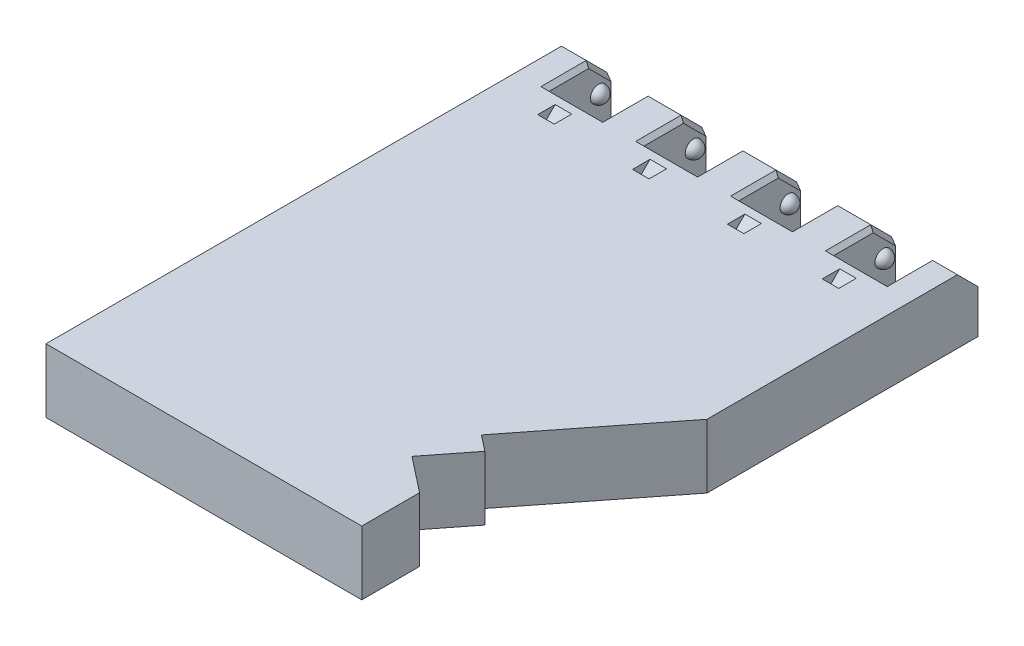
from build123d import *

# Parameters (mm, degrees)
BOSS_EXTRUDE1_DEPTH     = 15.5
SKETCH10_W              = 4
SKETCH10_H              = 30
CUT_EXTRUDE1_DEPTH      = 3
MIRROR5_COPY_1_SKETCH_W = 4
MIRROR5_COPY_1_SKETCH_H = 30
MIRROR5_COPY_1_DEPTH    = 3
SKETCH14_W              = 2.751713212
SKETCH14_H              = 4
BOSS_EXTRUDE2_DEPTH     = 4
SKETCH15_W              = 4.497862048
SKETCH15_H              = 7
BOSS_EXTRUDE3_DEPTH     = 1
MIRROR7_COPY_1_SKETCH_W = 2.751713212
MIRROR7_COPY_1_SKETCH_H = 4
MIRROR7_COPY_1_DEPTH    = 4
MIRROR7_COPY_2_SKETCH_W = 4.497862048
MIRROR7_COPY_2_SKETCH_H = 7
MIRROR7_COPY_2_DEPTH    = 1
CHAMFER9_SIZE           = 5
CHAMFER10_SIZE          = 1
CHAMFER15_SIZE          = 5
CHAMFER16_SIZE          = 1
CHAMFER17_SIZE          = 1
CHAMFER18_SIZE          = 5
CHAMFER19_SIZE          = 1


with BuildPart() as part:
    # Sketch1 → Boss-Extrude1 (new body)
    with BuildSketch(Plane(origin=(0, 0, 0), x_dir=(1, 0, 0), z_dir=(0, 1, 0))):
        Polygon((-106.77339112, 72.768445428), (-99.77339112, 72.768445428), (-99.77339112, 56.768445428), (-86.77339112, 56.768445428), (-86.77339112, 72.768445428), (-76.77339112, 72.768445428), (-76.77339112, 56.768445428), (-63.77339112, 56.768445428), (-63.77339112, 72.768445428), (-53.77339112, 72.768445428), (-53.77339112, 56.768445428), (-40.77339112, 56.768445428), (-40.77339112, 72.768445428), (-30.77339112, 72.768445428), (-30.77339112, 56.768445428), (-17.77339112, 56.768445428), (-17.77339112, 72.768445428), (-10.77339112, 72.768445428), (-10.77339112, 7.054306764), (-34.835725148, -23.581828326), (-30.98324076, -26.60765929), (-38.753655744, -36.500942414), (-30.205167067, -43.215124519), (-30.205167067, -57.231554572), (-106.77339112, -57.231554572), align=None)
    extrude(amount=BOSS_EXTRUDE1_DEPTH)

    # Sketch4 → Revolve1 (revolve)
    with BuildSketch(Plane(origin=(-99.77339112, 0, 0), x_dir=(0, 0, -1), z_dir=(1, 0, 0))):
        with BuildLine():
            Line((67.768445428, 8), (71.768445428, 8))
            ThreePointArc((71.768445428, 8), (69.768445428, 10), (67.768445428, 8))
        make_face()
    revolve1 = revolve(axis=Axis((-99.77339112, 8, -67.768445428), (0, 0, -1)))

    # Mirror1: Revolve1 across plane
    add(revolve1.mirror(Plane(origin=(-93.27339112, 0, 0), x_dir=(0, 0, 1), z_dir=(1, 0, 0))))

    # Mirror2: Revolve1 across plane
    add(revolve1.mirror(Plane(origin=(-81.77339112, 0, 0), x_dir=(0, 0, 1), z_dir=(1, 0, 0))))

    # Mirror2 copy 1 sketch → Mirror2 copy 1 (revolve)
    with BuildSketch(Plane(origin=(-76.77339112, 0, 0), x_dir=(0, 0, -1), z_dir=(1, 0, 0))):
        with BuildLine():
            Line((67.768445428, 8), (71.768445428, 8))
            ThreePointArc((71.768445428, 8), (69.768445428, 10), (67.768445428, 8))
        make_face()
    revolve(axis=Axis((-76.77339112, 8, -67.768445428), (0, 0, -1)))

    # Mirror3: Revolve1 across plane
    add(revolve1.mirror(Plane(origin=(-58.77339112, 0, 0), x_dir=(0, 0, 1), z_dir=(1, 0, 0))))

    # Mirror3 copy 1 sketch → Mirror3 copy 1 (revolve)
    with BuildSketch(Plane(origin=(-53.77339112, 0, 0), x_dir=(0, 0, -1), z_dir=(1, 0, 0))):
        with BuildLine():
            Line((67.768445428, 8), (71.768445428, 8))
            ThreePointArc((71.768445428, 8), (69.768445428, 10), (67.768445428, 8))
        make_face()
    revolve(axis=Axis((-53.77339112, 8, -67.768445428), (0, 0, -1)))

    # Mirror3 copy 2 sketch → Mirror3 copy 2 (revolve)
    with BuildSketch(Plane(origin=(-40.77339112, 0, 0), x_dir=(0, 0, -1), z_dir=(-1, 0, 0))):
        with BuildLine():
            Line((67.768445428, -8), (71.768445428, -8))
            ThreePointArc((71.768445428, -8), (69.768445428, -10), (67.768445428, -8))
        make_face()
    revolve(axis=Axis((-40.77339112, 8, -67.768445428), (0, 0, 1)))

    # Mirror3 copy 3 sketch → Mirror3 copy 3 (revolve)
    with BuildSketch(Plane(origin=(-30.77339112, 0, 0), x_dir=(0, 0, -1), z_dir=(1, 0, 0))):
        with BuildLine():
            Line((67.768445428, 8), (71.768445428, 8))
            ThreePointArc((71.768445428, 8), (69.768445428, 10), (67.768445428, 8))
        make_face()
    revolve(axis=Axis((-30.77339112, 8, -67.768445428), (0, 0, -1)))

    # Sketch10 → Cut-Extrude1 (cut)
    with BuildSketch(Plane(origin=(0, -17.5, -17.5), x_dir=(-1, 0, 0), z_dir=(0, -0.707106781, -0.707106781))):
        with Locations((24.27339112, 40.141352719)):
            Rectangle(SKETCH10_W, SKETCH10_H)
    cut_extrude1 = extrude(amount=CUT_EXTRUDE1_DEPTH, mode=Mode.SUBTRACT)

    # Mirror4: Cut-Extrude1 across plane
    add(cut_extrude1.mirror(Plane(origin=(-35.77339112, 0, 0), x_dir=(0, 0, 1), z_dir=(1, 0, 0))), mode=Mode.SUBTRACT)

    # Mirror5: Cut-Extrude1 across plane
    add(cut_extrude1.mirror(Plane(origin=(-58.77339112, 0, 0), x_dir=(0, 0, 1), z_dir=(1, 0, 0))), mode=Mode.SUBTRACT)

    # Mirror5 copy 1 sketch → Mirror5 copy 1 (cut)
    with BuildSketch(Plane(origin=(-46, -17.5, -17.5), x_dir=(-1, 0, 0), z_dir=(0, -0.707106781, -0.707106781))):
        with Locations((24.27339112, 40.141352719)):
            Rectangle(MIRROR5_COPY_1_SKETCH_W, MIRROR5_COPY_1_SKETCH_H)
    extrude(amount=MIRROR5_COPY_1_DEPTH, mode=Mode.SUBTRACT)

    # Sketch14 → Boss-Extrude2 (add)
    with BuildSketch(Plane(origin=(0, 0, 0), x_dir=(-1, 0, 0), z_dir=(0, -1, 0))):
        with Locations((24.227451545, 51.242640687)):
            Rectangle(SKETCH14_W, SKETCH14_H)
    boss_extrude2 = extrude(amount=BOSS_EXTRUDE2_DEPTH)

    # Sketch15 → Boss-Extrude3 (add)
    with BuildSketch(Plane.XZ.offset(4)):
        with Locations((-24.227451545, -51.242640687)):
            Rectangle(SKETCH15_W, SKETCH15_H)
    boss_extrude3 = extrude(amount=BOSS_EXTRUDE3_DEPTH)

    # Mirror6: Boss-Extrude2, Boss-Extrude3 across plane
    add(boss_extrude2.mirror(Plane(origin=(-35.77339112, 0, 0), x_dir=(0, 0, 1), z_dir=(1, 0, 0))))
    add(boss_extrude3.mirror(Plane(origin=(-35.77339112, 0, 0), x_dir=(0, 0, 1), z_dir=(1, 0, 0))))

    # Mirror7: Boss-Extrude2, Boss-Extrude3 across plane
    add(boss_extrude2.mirror(Plane(origin=(-58.77339112, 0, 0), x_dir=(0, 0, 1), z_dir=(1, 0, 0))))
    add(boss_extrude3.mirror(Plane(origin=(-58.77339112, 0, 0), x_dir=(0, 0, 1), z_dir=(1, 0, 0))))

    # Mirror7 copy 1 sketch → Mirror7 copy 1 (add)
    with BuildSketch(Plane(origin=(-46, 0, 0), x_dir=(-1, 0, 0), z_dir=(0, -1, 0))):
        with Locations((24.227451545, 51.242640687)):
            Rectangle(MIRROR7_COPY_1_SKETCH_W, MIRROR7_COPY_1_SKETCH_H)
    extrude(amount=MIRROR7_COPY_1_DEPTH)

    # Mirror7 copy 2 sketch → Mirror7 copy 2 (add)
    with BuildSketch(Plane(origin=(-46, -4, 0), x_dir=(1, 0, 0), z_dir=(0, -1, 0))):
        with Locations((-24.227451545, -51.242640687)):
            Rectangle(MIRROR7_COPY_2_SKETCH_W, MIRROR7_COPY_2_SKETCH_H)
    extrude(amount=MIRROR7_COPY_2_DEPTH)

    # Chamfer9
    chamfer9_edges = [part.edges().sort_by_distance(p)[0] for p in [
        (-103.27339112, 15.5, -72.768445428),
    ]]
    chamfer(chamfer9_edges, length=CHAMFER9_SIZE)

    # Chamfer10
    chamfer10_edges = [part.edges().sort_by_distance(p)[0] for p in [
        (-99.77339112, 15.5, -62.268445428),
        (-99.77339112, 13, -70.268445428),
    ]]
    chamfer(chamfer10_edges, length=CHAMFER10_SIZE)

    # Chamfer15
    chamfer15_edges = [part.edges().sort_by_distance(p)[0] for p in [
        (-81.77339112, 15.5, -72.768445428),
    ]]
    chamfer(chamfer15_edges, length=CHAMFER15_SIZE)

    # Chamfer16
    chamfer16_edges = [part.edges().sort_by_distance(p)[0] for p in [
        (-86.77339112, 13, -70.268445428),
        (-86.77339112, 15.5, -62.268445428),
    ]]
    chamfer(chamfer16_edges, length=CHAMFER16_SIZE)

    # Chamfer17
    chamfer17_edges = [part.edges().sort_by_distance(p)[0] for p in [
        (-76.77339112, 15.5, -62.268445428),
        (-76.77339112, 13, -70.268445428),
    ]]
    chamfer(chamfer17_edges, length=CHAMFER17_SIZE)

    # Chamfer18
    chamfer18_edges = [part.edges().sort_by_distance(p)[0] for p in [
        (-14.27339112, 15.5, -72.768445428),
        (-35.77339112, 15.5, -72.768445428),
        (-58.77339112, 15.5, -72.768445428),
    ]]
    chamfer(chamfer18_edges, length=CHAMFER18_SIZE)

    # Chamfer19
    chamfer19_edges = [part.edges().sort_by_distance(p)[0] for p in [
        (-17.77339112, 15.5, -62.268445428),
        (-40.77339112, 15.5, -62.268445428),
        (-30.77339112, 15.5, -62.268445428),
        (-53.77339112, 15.5, -62.268445428),
        (-17.77339112, 13, -70.268445428),
        (-30.77339112, 13, -70.268445428),
        (-40.77339112, 13, -70.268445428),
        (-53.77339112, 13, -70.268445428),
        (-63.77339112, 13, -70.268445428),
        (-63.77339112, 15.5, -62.268445428),
    ]]
    chamfer(chamfer19_edges, length=CHAMFER19_SIZE)


solid = part.part
